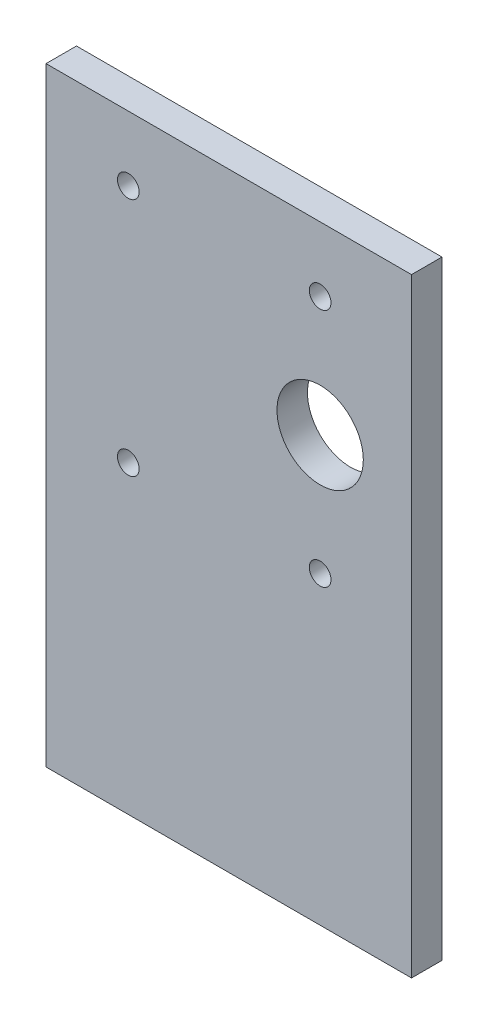
from build123d import *

# Parameters (mm, degrees)
SKETCH1_W             = 38.1
SKETCH1_H             = 63.5
BOSS_EXTRUDE1_DEPTH   = 3.175
F_4_40_TAPPED_HOLE1_D = 2.2606
SKETCH2_R             = 4.5
CUT_EXTRUDE1_DEPTH    = 3.175


with BuildPart() as part:
    # Sketch1 → Boss-Extrude1 (new body)
    with BuildSketch(Plane.XY):
        with Locations((1.3783859, -15.668831169)):
            Rectangle(SKETCH1_W, SKETCH1_H)
    extrude(amount=BOSS_EXTRUDE1_DEPTH)

    # #4-40 Tapped Hole1 (through all)
    with Locations(Plane.XY.offset(3.175)):
        with Locations((10.9033859, 9.336044502), (10.9033859, -15.663955498), (-9.0966141, -15.663955498), (-9.0966141, 9.336044502)):
            Hole(F_4_40_TAPPED_HOLE1_D / 2)

    # Sketch2 → Cut-Extrude1 (cut)
    with BuildSketch(Plane.XY.offset(3.175)):
        with Locations((10.9033859, -3.163955498)):
            Circle(SKETCH2_R)
    extrude(amount=-CUT_EXTRUDE1_DEPTH, mode=Mode.SUBTRACT)


solid = part.part
